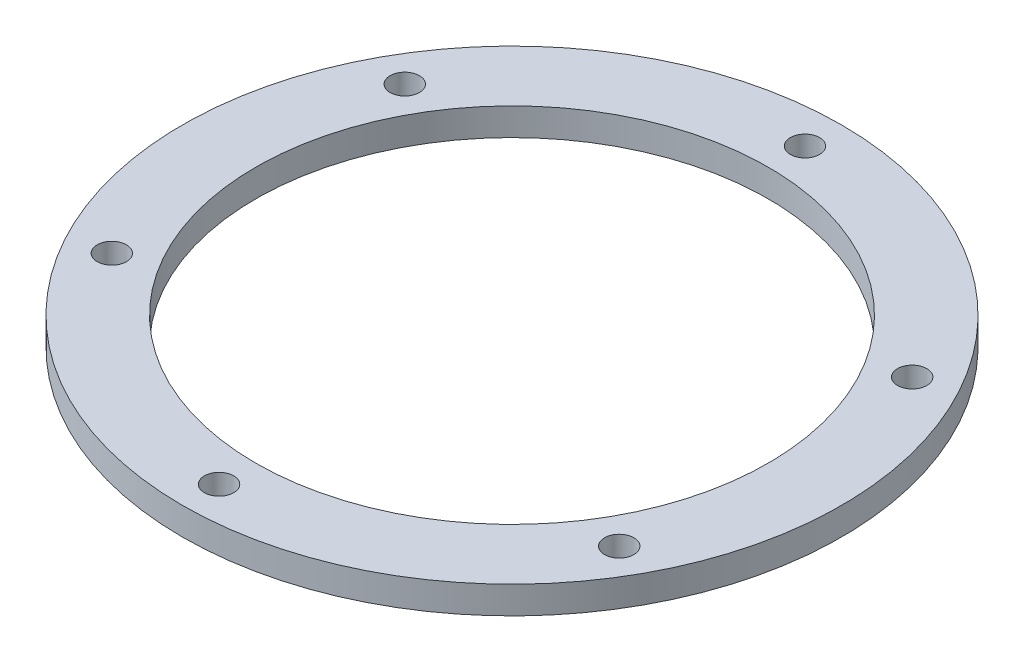
from build123d import *

# Parameters (mm, degrees)
SKETCH_1_R      = 36
SKETCH_1_R_2    = 1.6
SKETCH_1_R_3    = 28
EXTRUDE_1_DEPTH = 3


with BuildPart() as part:
    # Эскиз1 → Бобышка-Вытянуть1 (new body)
    with BuildSketch(Plane(origin=(0, 0, 0), x_dir=(1, 0, 0), z_dir=(0, 1, 0))):
        Circle(SKETCH_1_R)
        with Locations((0, -32)):
            Circle(SKETCH_1_R_2, mode=Mode.SUBTRACT)
        with Locations((-27.712812921, -16)):
            Circle(SKETCH_1_R_2, mode=Mode.SUBTRACT)
        with Locations((-27.712812921, 16)):
            Circle(SKETCH_1_R_2, mode=Mode.SUBTRACT)
        with Locations((0, 32)):
            Circle(SKETCH_1_R_2, mode=Mode.SUBTRACT)
        with Locations((27.712812921, 16)):
            Circle(SKETCH_1_R_2, mode=Mode.SUBTRACT)
        with Locations((27.712812921, -16)):
            Circle(SKETCH_1_R_2, mode=Mode.SUBTRACT)
        Circle(SKETCH_1_R_3, mode=Mode.SUBTRACT)
    extrude(amount=EXTRUDE_1_DEPTH)


solid = part.part
